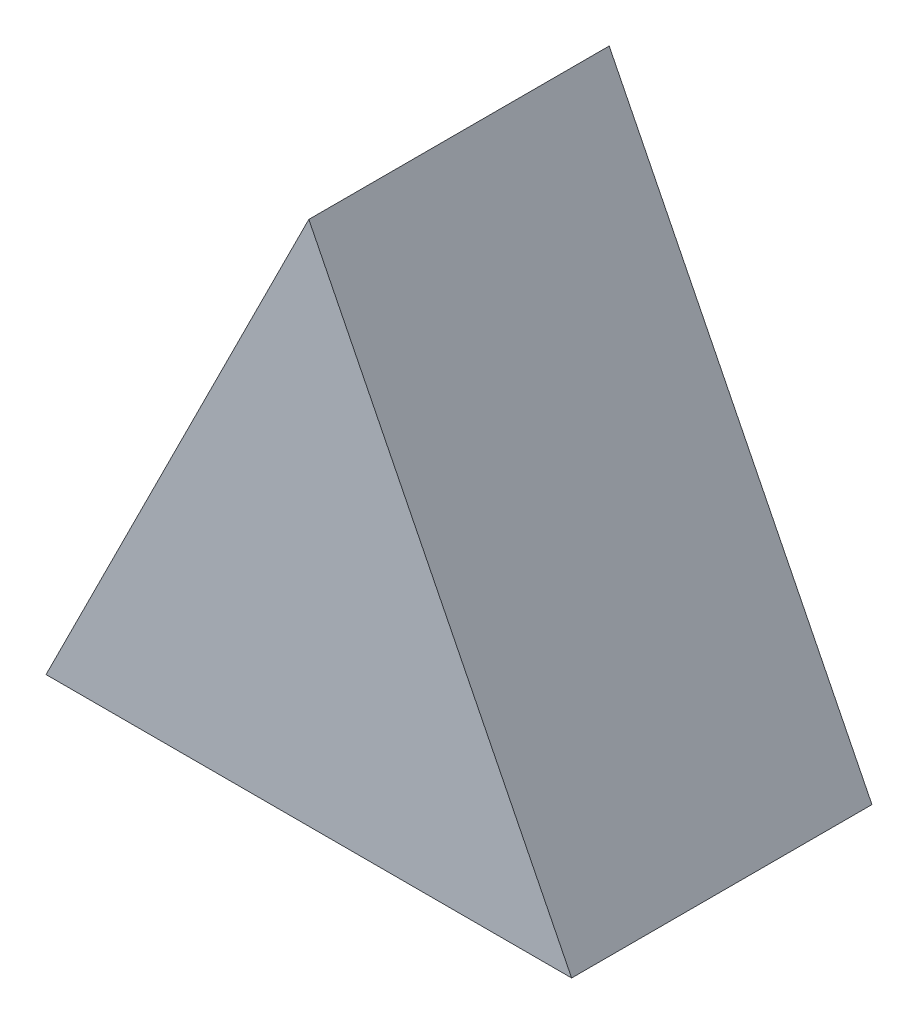
from build123d import *

# Parameters (mm, degrees)
BOSS_EXTRUDE1_DEPTH = 20


with BuildPart() as part:
    # Sketch1 → Boss-Extrude1 (new body)
    with BuildSketch(Plane.XY):
        Polygon((-5.765895954, 17.702312139), (11.734104046, -17.297687861), (-23.265895954, -17.297687861), align=None)
    extrude(amount=BOSS_EXTRUDE1_DEPTH)


solid = part.part
